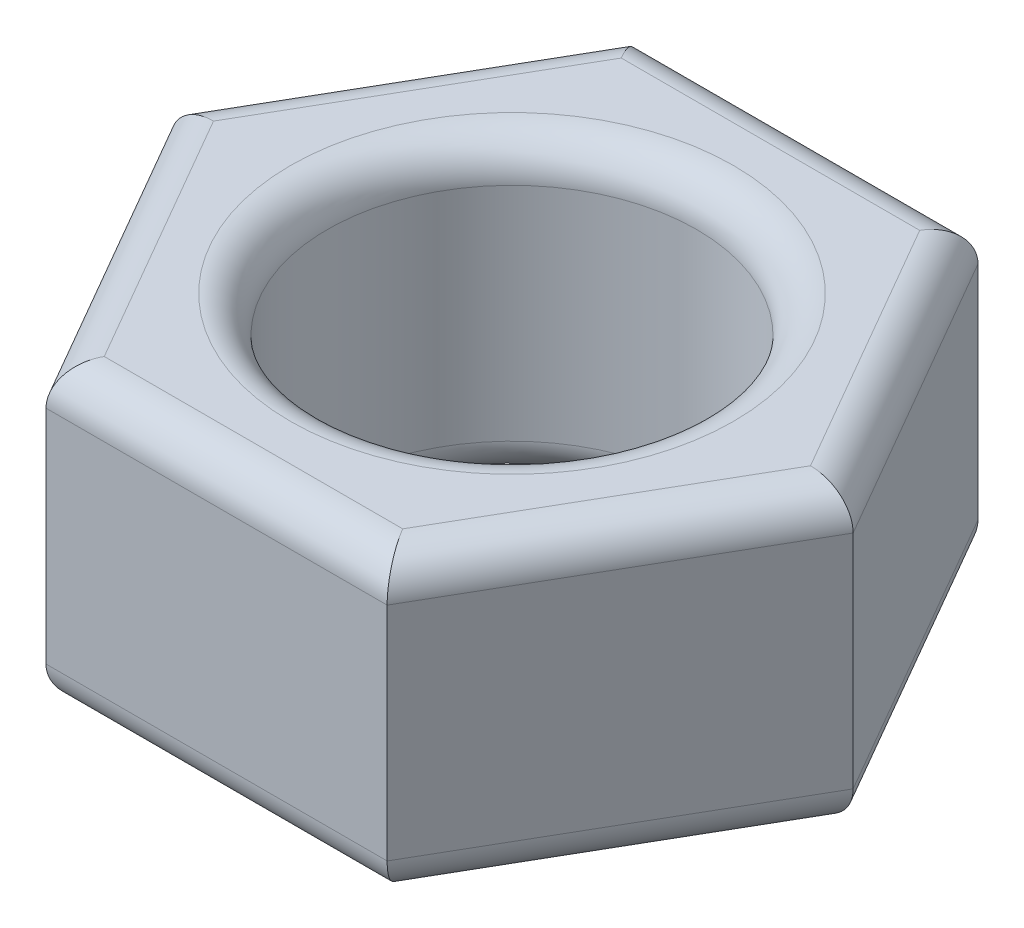
from build123d import *

# Parameters (mm, degrees)
SKETCH1_R           = 2.5
BOSS_EXTRUDE1_DEPTH = 4
FILLET1_R           = 0.5
FILLET4_R           = 0.5
FILLET5_R           = 0.5


with BuildPart() as part:
    # Sketch1 → Boss-Extrude1 (new body)
    with BuildSketch(Plane(origin=(0, 0, 0), x_dir=(1, 0, 0), z_dir=(0, 1, 0))):
        Polygon((-4.618802154, 0), (-2.309401077, -4), (2.309401077, -4), (4.618802154, 0), (2.309401077, 4), (-2.309401077, 4), align=None)
        Circle(SKETCH1_R, mode=Mode.SUBTRACT)
    extrude(amount=BOSS_EXTRUDE1_DEPTH)

    # Fillet1
    fillet1_edges = [part.edges().sort_by_distance(p)[0] for p in [
        (0, 4, -4),
        (-3.464101615, 4, -2),
        (-3.464101615, 4, 2),
        (0, 4, 4),
        (3.464101615, 4, 2),
        (3.464101615, 4, -2),
    ]]
    fillet(fillet1_edges, radius=FILLET1_R)

    # Fillet4
    fillet4_edges = [part.edges().sort_by_distance(p)[0] for p in [
        (-2.5, 0, 0),
        (0, 0, 4),
        (-3.464101615, 0, 2),
        (-3.464101615, 0, -2),
        (0, 0, -4),
        (3.464101615, 0, -2),
        (3.464101615, 0, 2),
    ]]
    fillet(fillet4_edges, radius=FILLET4_R)

    # Fillet5
    fillet5_edges = [part.edges().sort_by_distance(p)[0] for p in [
        (-2.5, 4, 0),
    ]]
    fillet(fillet5_edges, radius=FILLET5_R)


solid = part.part
